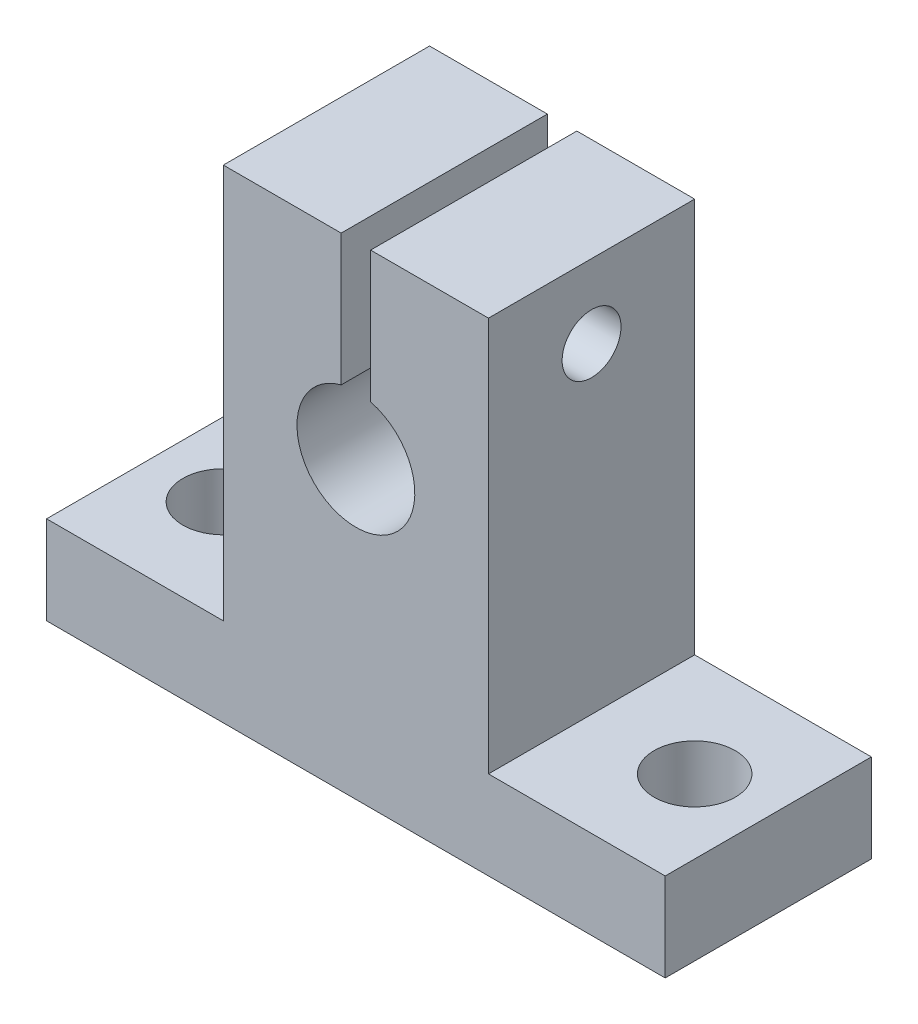
from build123d import *

# Parameters (mm, degrees)
EXTRUDE_1_DEPTH     = 14
SKETCH_2_R          = 4
SKETCH_2_W          = 2
SKETCH_2_H          = 8.927016654
CUT_EXTRUDE_2_DEPTH = 14
CUT_EXTRUDE_3_REACH = 34.8
SKETCH_4_R          = 2.75
SKETCH_5_R          = 2
CUT_EXTRUDE_4_DEPTH = 18
SKETCH_6_R          = 3.5
CUT_EXTRUDE_5_DEPTH = 4


with BuildPart() as part:
    # 草图1 → 凸台-拉伸1 (new body)
    with BuildSketch(Plane.XY):
        Polygon((21, 0), (-21, 0), (-21, 6), (-9, 6), (-9, 32.8), (9, 32.8), (9, 6), (21, 6), align=None)
    extrude(amount=EXTRUDE_1_DEPTH)

    # 草图2 → 切除-拉伸2 (cut)
    with BuildSketch(Plane(origin=(0, 0, 0), x_dir=(-1, 0, 0), z_dir=(0, 0, -1))):
        with Locations((0, 20)):
            Circle(SKETCH_2_R)
        with Locations((0, 28.336491673)):
            Rectangle(SKETCH_2_W, SKETCH_2_H)
    extrude(amount=-CUT_EXTRUDE_2_DEPTH, mode=Mode.SUBTRACT)

    # 草图4 → 切除-拉伸3 (cut, up to next)
    with BuildSketch(Plane.XZ, mode=Mode.PRIVATE) as cut_extrude_3_sk1:
        with Locations((16, 7)):
            Circle(SKETCH_4_R)
    cut_extrude_3_tool1 = extrude(cut_extrude_3_sk1.sketch, amount=-CUT_EXTRUDE_3_REACH, mode=Mode.PRIVATE) & part.part
    add(cut_extrude_3_tool1.solids().sort_by_distance((16, 0, 7))[0], mode=Mode.SUBTRACT)
    # 草图4 → 切除-拉伸3 (cut, up to next)
    with BuildSketch(Plane.XZ, mode=Mode.PRIVATE) as cut_extrude_3_sk2:
        with Locations((-16, 7)):
            Circle(SKETCH_4_R)
    cut_extrude_3_tool2 = extrude(cut_extrude_3_sk2.sketch, amount=-CUT_EXTRUDE_3_REACH, mode=Mode.PRIVATE) & part.part
    add(cut_extrude_3_tool2.solids().sort_by_distance((-16, 0, 7))[0], mode=Mode.SUBTRACT)

    # 草图5 → 切除-拉伸4 (cut)
    with BuildSketch(Plane.ZY.offset(9)):
        with Locations((7, 27.8)):
            Circle(SKETCH_5_R)
    extrude(amount=-CUT_EXTRUDE_4_DEPTH, mode=Mode.SUBTRACT)

    # 草图6 → 切除-拉伸5 (cut)
    with BuildSketch(Plane.ZY.offset(9)):
        with Locations((7, 27.8)):
            Circle(SKETCH_6_R)
    extrude(amount=-CUT_EXTRUDE_5_DEPTH, mode=Mode.SUBTRACT)


solid = part.part
